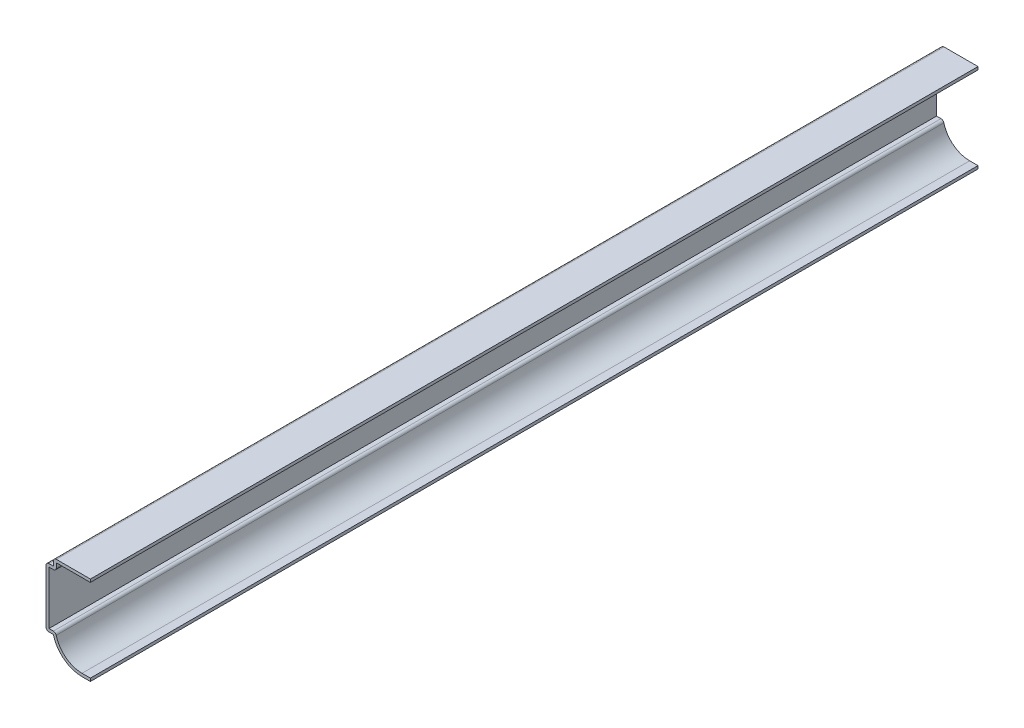
from build123d import *

# Parameters (mm, degrees)
EXTRUDE_THIN1_DEPTH = 381
FILLET1_R           = 1.27


with BuildPart() as part:
    # Sketch1 → Extrude-Thin1 (new body)
    with BuildSketch(Plane.XY):
        with BuildLine():
            Line((0, 0), (-3.578277876, 0))
            ThreePointArc((-3.578277876, 0), (-11.355407809, 2.659768429), (-15.875, 9.525))
            Line((-15.875, 9.525), (-19.05, 9.525))
            Line((-19.05, 9.525), (-19.05, 34.925))
            Line((-19.05, 34.925), (-15.875, 34.925))
            Line((-15.875, 34.925), (-15.875, 38.1))
            Line((-15.875, 38.1), (0, 38.1))
            Line((0, 38.1), (0, 36.83))
            Line((0, 36.83), (-14.605, 36.83))
            Line((-14.605, 36.83), (-14.605, 33.655))
            Line((-14.605, 33.655), (-17.78, 33.655))
            Line((-17.78, 33.655), (-17.78, 10.795))
            Line((-17.78, 10.795), (-14.848409863, 10.795))
            ThreePointArc((-14.848409863, 10.795), (-10.95631115, 3.970193301), (-3.578277876, 1.27))
            Line((-3.578277876, 1.27), (0, 1.27))
            Line((0, 1.27), (0, 0))
        make_face()
    extrude(amount=-EXTRUDE_THIN1_DEPTH)

    # Fillet1
    fillet1_edges = [part.edges().sort_by_distance(p)[0] for p in [
        (-14.605, 33.655, -190.5),
        (-14.848409863, 10.795, -190.5),
        (-19.05, 9.525, -190.5),
        (-19.05, 34.925, -190.5),
        (-15.875, 38.1, -190.5),
    ]]
    fillet(fillet1_edges, radius=FILLET1_R)


solid = part.part
